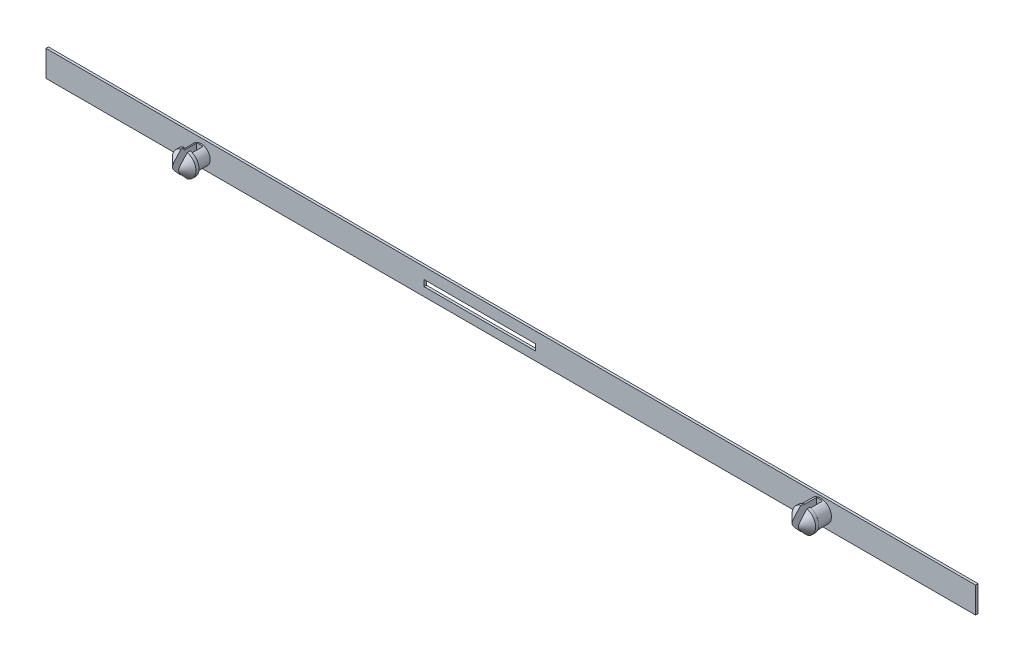
from build123d import *

# Parameters (mm, degrees)
SKICA2_W                 = 150
SKICA2_H                 = 4.2
SKICA2_W_2               = 18
SKICA2_H_2               = 1
P_IDAT_VYSUNUT_M2_DEPTH  = 0.4
SKICA3_R                 = 1.5
SKICA3_R_2               = 1.75
P_IDAT_VYSUNUT_M3_DEPTH  = 2.2
SKICA5_R                 = 1.9
P_IDAT_VYSUNUT_M5_DEPTH  = 2
ZKOSEN_2_SIZE            = 1.5
SKICA7_W                 = 1
SKICA7_H                 = 5
ODEBRAT_VYSUNUT_M1_DEPTH = 4


with BuildPart() as part:
    # Skica2 → Přidat vysunutím2 (new body)
    with BuildSketch(Plane.XY):
        Rectangle(SKICA2_W, SKICA2_H)
        with Locations((-5, -0.2)):
            Rectangle(SKICA2_W_2, SKICA2_H_2, mode=Mode.SUBTRACT)
    extrude(amount=P_IDAT_VYSUNUT_M2_DEPTH)

    # Skica3 → Přidat vysunutím3 (add)
    with BuildSketch(Plane.XY.offset(0.4)):
        with Locations((-50, -0.2)):
            Circle(SKICA3_R)
        with Locations((50, 0)):
            Circle(SKICA3_R_2)
    extrude(amount=P_IDAT_VYSUNUT_M3_DEPTH)

    # Skica5 → Přidat vysunutím5 (add)
    with BuildSketch(Plane.XY.offset(2.6)):
        with Locations((-50, -0.2)):
            Circle(SKICA5_R)
        with Locations((50, 0)):
            Circle(SKICA5_R)
    extrude(amount=P_IDAT_VYSUNUT_M5_DEPTH)

    # Zkosení2
    zkosen_2_edges = [part.edges().sort_by_distance(p)[0] for p in [
        (-51.9, -0.2, 4.6),
        (48.1, 0, 4.6),
    ]]
    chamfer(zkosen_2_edges, length=ZKOSEN_2_SIZE)

    # Skica7 → Odebrat vysunutím1 (cut)
    with BuildSketch(Plane.XY.offset(4.6)):
        with Locations((-50, -0.2)):
            Rectangle(SKICA7_W, SKICA7_H)
        with Locations((50, 0)):
            Rectangle(SKICA7_W, SKICA7_H)
    extrude(amount=-ODEBRAT_VYSUNUT_M1_DEPTH, mode=Mode.SUBTRACT)


solid = part.part
